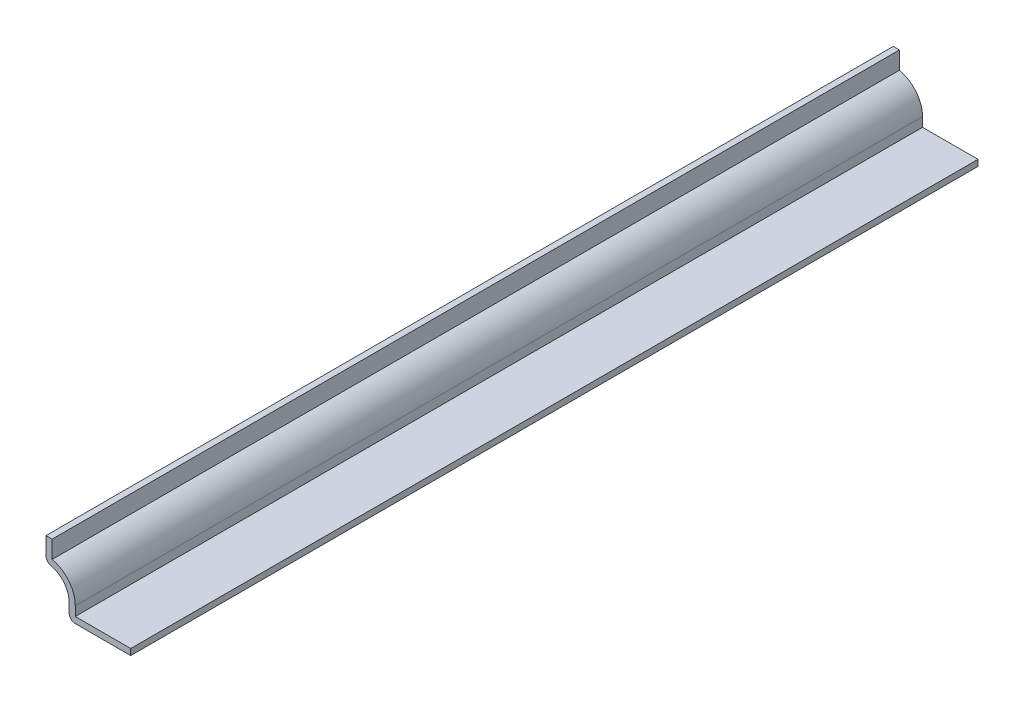
from build123d import *

# Parameters (mm, degrees)
EXTRUDE_THIN1_DEPTH = 174.625
FILLET1_R           = 1.27


with BuildPart() as part:
    # Sketch1 → Extrude-Thin1 (new body)
    with BuildSketch(Plane.XY):
        with BuildLine():
            Line((0, 0), (-12.7, 0))
            Line((-12.7, 0), (-12.7, 3.175))
            ThreePointArc((-12.7, 3.175), (-14.094903955, 6.542596045), (-17.4625, 7.9375))
            Line((-17.4625, 7.9375), (-17.4625, 12.7))
            Line((-17.4625, 12.7), (-16.1925, 12.7))
            Line((-16.1925, 12.7), (-16.1925, 9.07230076))
            ThreePointArc((-16.1925, 9.07230076), (-12.769295804, 6.965104303), (-11.43, 3.175))
            Line((-11.43, 3.175), (-11.43, 1.27))
            Line((-11.43, 1.27), (0, 1.27))
            Line((0, 1.27), (0, 0))
        make_face()
    extrude(amount=-EXTRUDE_THIN1_DEPTH)

    # Fillet1
    fillet1_edges = [part.edges().sort_by_distance(p)[0] for p in [
        (-12.7, 0, -87.3125),
        (-17.4625, 7.9375, -87.3125),
    ]]
    fillet(fillet1_edges, radius=FILLET1_R)


solid = part.part
